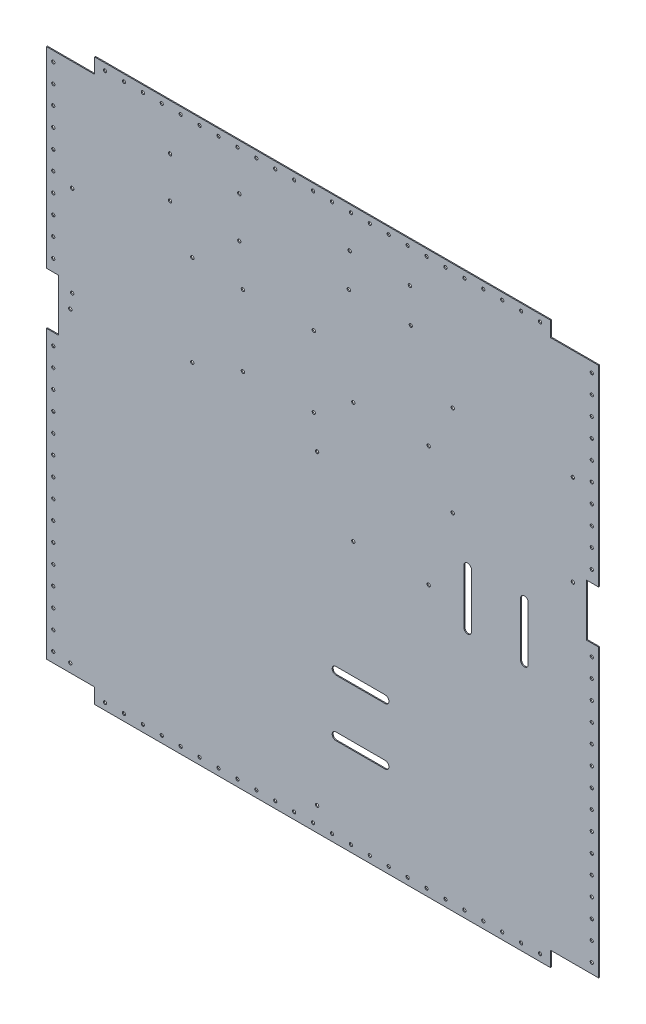
from build123d import *

# Parameters (mm, degrees)
BOSS_EXTRUDE1_DEPTH = 1.016
SKETCH2_R           = 1.675
CUT_EXTRUDE1_DEPTH  = 2.016
SKETCH8_R           = 1.75
CUT_EXTRUDE2_DEPTH  = 2.016
CUT_EXTRUDE3_DEPTH  = 2.016


with BuildPart() as part:
    # Sketch1 → Boss-Extrude1 (new body)
    with BuildSketch(Plane.XY):
        Polygon((0, 374), (0, 577), (51, 577), (51, 593), (533, 593), (533, 577), (584, 577), (584, 374), (571, 374), (571, 319), (584, 319), (584, 16), (533, 16), (533, 0), (51, 0), (51, 16), (0, 16), (0, 319), (13, 319), (13, 374), align=None)
    extrude(amount=BOSS_EXTRUDE1_DEPTH)

    # Sketch2 → Cut-Extrude1 (cut, through all)
    with BuildSketch(Plane.XY.offset(1.016)):
        with Locations((62, 585.825)):
            Circle(SKETCH2_R)
        with Locations((82, 585.825)):
            Circle(SKETCH2_R)
        with Locations((102, 585.825)):
            Circle(SKETCH2_R)
        with Locations((122, 585.825)):
            Circle(SKETCH2_R)
        with Locations((142, 585.825)):
            Circle(SKETCH2_R)
        with Locations((162, 585.825)):
            Circle(SKETCH2_R)
        with Locations((182, 585.825)):
            Circle(SKETCH2_R)
        with Locations((202, 585.825)):
            Circle(SKETCH2_R)
        with Locations((222, 585.825)):
            Circle(SKETCH2_R)
        with Locations((242, 585.825)):
            Circle(SKETCH2_R)
        with Locations((262, 585.825)):
            Circle(SKETCH2_R)
        with Locations((282, 585.825)):
            Circle(SKETCH2_R)
        with Locations((302, 585.825)):
            Circle(SKETCH2_R)
        with Locations((322, 585.825)):
            Circle(SKETCH2_R)
        with Locations((342, 585.825)):
            Circle(SKETCH2_R)
        with Locations((362, 585.825)):
            Circle(SKETCH2_R)
        with Locations((382, 585.825)):
            Circle(SKETCH2_R)
        with Locations((402, 585.825)):
            Circle(SKETCH2_R)
        with Locations((422, 585.825)):
            Circle(SKETCH2_R)
        with Locations((442, 585.825)):
            Circle(SKETCH2_R)
        with Locations((462, 585.825)):
            Circle(SKETCH2_R)
        with Locations((482, 585.825)):
            Circle(SKETCH2_R)
        with Locations((502, 585.825)):
            Circle(SKETCH2_R)
        with Locations((522, 585.825)):
            Circle(SKETCH2_R)
        with Locations((576.725, 566.5)):
            Circle(SKETCH2_R)
        with Locations((576.725, 546.5)):
            Circle(SKETCH2_R)
        with Locations((576.725, 526.5)):
            Circle(SKETCH2_R)
        with Locations((576.725, 506.5)):
            Circle(SKETCH2_R)
        with Locations((576.725, 486.5)):
            Circle(SKETCH2_R)
        with Locations((576.725, 466.5)):
            Circle(SKETCH2_R)
        with Locations((576.725, 446.5)):
            Circle(SKETCH2_R)
        with Locations((576.725, 426.5)):
            Circle(SKETCH2_R)
        with Locations((576.725, 406.5)):
            Circle(SKETCH2_R)
        with Locations((576.725, 386.5)):
            Circle(SKETCH2_R)
        with Locations((576.725, 306.5)):
            Circle(SKETCH2_R)
        with Locations((576.725, 286.5)):
            Circle(SKETCH2_R)
        with Locations((576.725, 266.5)):
            Circle(SKETCH2_R)
        with Locations((576.725, 246.5)):
            Circle(SKETCH2_R)
        with Locations((576.725, 226.5)):
            Circle(SKETCH2_R)
        with Locations((576.725, 206.5)):
            Circle(SKETCH2_R)
        with Locations((576.725, 186.5)):
            Circle(SKETCH2_R)
        with Locations((576.725, 166.5)):
            Circle(SKETCH2_R)
        with Locations((576.725, 146.5)):
            Circle(SKETCH2_R)
        with Locations((576.725, 126.5)):
            Circle(SKETCH2_R)
        with Locations((576.725, 106.5)):
            Circle(SKETCH2_R)
        with Locations((576.725, 86.5)):
            Circle(SKETCH2_R)
        with Locations((576.725, 66.5)):
            Circle(SKETCH2_R)
        with Locations((576.725, 46.5)):
            Circle(SKETCH2_R)
        with Locations((576.725, 26.5)):
            Circle(SKETCH2_R)
        with Locations((522, 7.175)):
            Circle(SKETCH2_R)
        with Locations((502, 7.175)):
            Circle(SKETCH2_R)
        with Locations((482, 7.175)):
            Circle(SKETCH2_R)
        with Locations((462, 7.175)):
            Circle(SKETCH2_R)
        with Locations((442, 7.175)):
            Circle(SKETCH2_R)
        with Locations((422, 7.175)):
            Circle(SKETCH2_R)
        with Locations((402, 7.175)):
            Circle(SKETCH2_R)
        with Locations((382, 7.175)):
            Circle(SKETCH2_R)
        with Locations((362, 7.175)):
            Circle(SKETCH2_R)
        with Locations((342, 7.175)):
            Circle(SKETCH2_R)
        with Locations((322, 7.175)):
            Circle(SKETCH2_R)
        with Locations((302, 7.175)):
            Circle(SKETCH2_R)
        with Locations((282, 7.175)):
            Circle(SKETCH2_R)
        with Locations((262, 7.175)):
            Circle(SKETCH2_R)
        with Locations((242, 7.175)):
            Circle(SKETCH2_R)
        with Locations((222, 7.175)):
            Circle(SKETCH2_R)
        with Locations((202, 7.175)):
            Circle(SKETCH2_R)
        with Locations((182, 7.175)):
            Circle(SKETCH2_R)
        with Locations((162, 7.175)):
            Circle(SKETCH2_R)
        with Locations((142, 7.175)):
            Circle(SKETCH2_R)
        with Locations((122, 7.175)):
            Circle(SKETCH2_R)
        with Locations((102, 7.175)):
            Circle(SKETCH2_R)
        with Locations((62, 7.175)):
            Circle(SKETCH2_R)
        with Locations((82, 7.175)):
            Circle(SKETCH2_R)
        with Locations((7.275, 26.5)):
            Circle(SKETCH2_R)
        with Locations((7.275, 46.5)):
            Circle(SKETCH2_R)
        with Locations((7.275, 66.5)):
            Circle(SKETCH2_R)
        with Locations((7.275, 86.5)):
            Circle(SKETCH2_R)
        with Locations((7.275, 106.5)):
            Circle(SKETCH2_R)
        with Locations((7.275, 126.5)):
            Circle(SKETCH2_R)
        with Locations((7.275, 146.5)):
            Circle(SKETCH2_R)
        with Locations((7.275, 166.5)):
            Circle(SKETCH2_R)
        with Locations((7.275, 186.5)):
            Circle(SKETCH2_R)
        with Locations((7.275, 206.5)):
            Circle(SKETCH2_R)
        with Locations((7.275, 226.5)):
            Circle(SKETCH2_R)
        with Locations((7.275, 246.5)):
            Circle(SKETCH2_R)
        with Locations((7.275, 266.5)):
            Circle(SKETCH2_R)
        with Locations((7.275, 286.5)):
            Circle(SKETCH2_R)
        with Locations((7.275, 306.5)):
            Circle(SKETCH2_R)
        with Locations((7.275, 386.5)):
            Circle(SKETCH2_R)
        with Locations((7.275, 406.5)):
            Circle(SKETCH2_R)
        with Locations((7.275, 426.5)):
            Circle(SKETCH2_R)
        with Locations((7.275, 446.5)):
            Circle(SKETCH2_R)
        with Locations((7.275, 466.5)):
            Circle(SKETCH2_R)
        with Locations((7.275, 486.5)):
            Circle(SKETCH2_R)
        with Locations((7.275, 506.5)):
            Circle(SKETCH2_R)
        with Locations((7.275, 526.5)):
            Circle(SKETCH2_R)
        with Locations((7.275, 546.5)):
            Circle(SKETCH2_R)
        with Locations((7.275, 566.5)):
            Circle(SKETCH2_R)
    extrude(amount=-CUT_EXTRUDE1_DEPTH, mode=Mode.SUBTRACT)

    # Sketch8 → Cut-Extrude2 (cut, through all)
    with BuildSketch(Plane.XY.offset(1.016)):
        with Locations((130.780438588, 544.221739262)):
            Circle(SKETCH8_R)
        with Locations((203.980438588, 544.221739262)):
            Circle(SKETCH8_R)
        with Locations((130.780438588, 501.021739262)):
            Circle(SKETCH8_R)
        with Locations((203.980438588, 501.021739262)):
            Circle(SKETCH8_R)
        with Locations((320.775, 550.325)):
            Circle(SKETCH8_R)
        with Locations((319.775, 514.325)):
            Circle(SKETCH8_R)
        with Locations((385.375, 514.325)):
            Circle(SKETCH8_R)
        with Locations((384.375, 550.325)):
            Circle(SKETCH8_R)
        with Locations((429.725, 460.825)):
            Circle(SKETCH8_R)
        with Locations((556.725, 460.825)):
            Circle(SKETCH8_R)
        with Locations((556.725, 364.825)):
            Circle(SKETCH8_R)
        with Locations((429.725, 364.825)):
            Circle(SKETCH8_R)
        with Locations((324.55, 413.325)):
            Circle(SKETCH8_R)
        with Locations((404.225, 413.325)):
            Circle(SKETCH8_R)
        with Locations((324.55, 286.025)):
            Circle(SKETCH8_R)
        with Locations((404.225, 286.025)):
            Circle(SKETCH8_R)
        with Locations((286.275, 25.175)):
            Circle(SKETCH8_R)
        with Locations((25.275, 25.175)):
            Circle(SKETCH8_R)
        with Locations((25.275, 349.175)):
            Circle(SKETCH8_R)
        with Locations((286.275, 349.175)):
            Circle(SKETCH8_R)
        with Locations((154.275, 460.825)):
            Circle(SKETCH8_R)
        with Locations((27.275, 460.825)):
            Circle(SKETCH8_R)
        with Locations((27.275, 364.825)):
            Circle(SKETCH8_R)
        with Locations((154.275, 364.825)):
            Circle(SKETCH8_R)
        with Locations((207.775, 458.325)):
            Circle(SKETCH8_R)
        with Locations((207.775, 383.325)):
            Circle(SKETCH8_R)
        with Locations((282.775, 458.325)):
            Circle(SKETCH8_R)
        with Locations((282.775, 383.325)):
            Circle(SKETCH8_R)
    extrude(amount=-CUT_EXTRUDE2_DEPTH, mode=Mode.SUBTRACT)

    # Sketch9 → Cut-Extrude3 (cut, through all)
    with BuildSketch(Plane.XY.offset(1.016)):
        with BuildLine():
            Line((501.475, 265.675), (501.475, 322.675))
            ThreePointArc((501.475, 322.675), (505.475, 326.675), (509.475, 322.675))
            Line((509.475, 322.675), (509.475, 265.675))
            ThreePointArc((509.475, 265.675), (505.475, 261.675), (501.475, 265.675))
        make_face()
        with BuildLine():
            Line((441.475, 265.675), (441.475, 322.675))
            ThreePointArc((441.475, 322.675), (445.475, 326.675), (449.475, 322.675))
            Line((449.475, 322.675), (449.475, 265.675))
            ThreePointArc((449.475, 265.675), (445.475, 261.675), (441.475, 265.675))
        make_face()
        with BuildLine():
            Line((358.225, 154.425), (306.225, 154.425))
            ThreePointArc((306.225, 154.425), (302.225, 158.425), (306.225, 162.425))
            Line((306.225, 162.425), (358.225, 162.425))
            ThreePointArc((358.225, 162.425), (362.225, 158.425), (358.225, 154.425))
        make_face()
        with BuildLine():
            Line((306.225, 102.425), (358.225, 102.425))
            ThreePointArc((358.225, 102.425), (362.225, 98.425), (358.225, 94.425))
            Line((358.225, 94.425), (306.225, 94.425))
            ThreePointArc((306.225, 94.425), (302.225, 98.425), (306.225, 102.425))
        make_face()
    extrude(amount=-CUT_EXTRUDE3_DEPTH, mode=Mode.SUBTRACT)


solid = part.part
